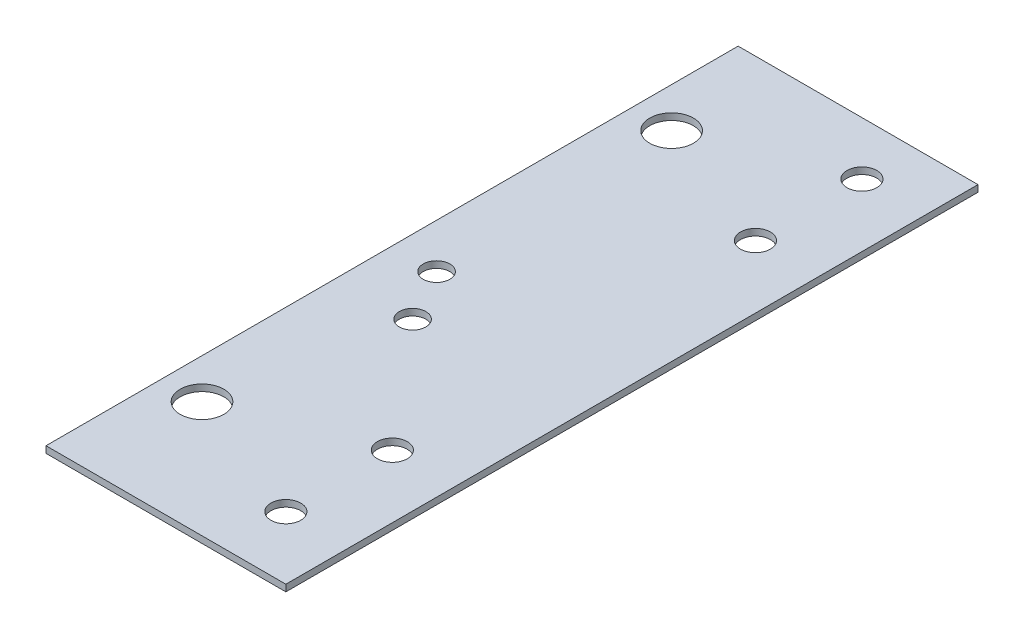
from build123d import *

# Parameters (mm, degrees)
SKETCH1_R           = 5.207
SKETCH1_R_2         = 3.556
BOSS_EXTRUDE1_DEPTH = 1.5875
SKETCH2_R           = 3.175
CUT_EXTRUDE1_DEPTH  = 2.5875
SKETCH3_R           = 3.175
CUT_EXTRUDE2_DEPTH  = 2.5875


with BuildPart() as part:
    # Sketch1 → Boss-Extrude1 (new body)
    with BuildSketch(Plane(origin=(0, 0, 0), x_dir=(1, 0, 0), z_dir=(0, 1, 0))):
        Polygon((-28.60675, 81.407), (28.60675, 81.407), (28.60675, -81.407), (28.60675, -83.693), (-28.60675, -83.693), (-28.60675, -81.407), align=None)
        with Locations((-19.08175, 56.007)):
            Circle(SKETCH1_R, mode=Mode.SUBTRACT)
        with Locations((-19.08175, -56.007)):
            Circle(SKETCH1_R, mode=Mode.SUBTRACT)
        with Locations((13.62075, 68.707)):
            Circle(SKETCH1_R_2, mode=Mode.SUBTRACT)
        with Locations((13.62075, 43.307)):
            Circle(SKETCH1_R_2, mode=Mode.SUBTRACT)
        with Locations((13.62075, -43.307)):
            Circle(SKETCH1_R_2, mode=Mode.SUBTRACT)
        with Locations((13.62075, -68.707)):
            Circle(SKETCH1_R_2, mode=Mode.SUBTRACT)
    extrude(amount=BOSS_EXTRUDE1_DEPTH)

    # Sketch2 → Cut-Extrude1 (cut, through all)
    with BuildSketch(Plane(origin=(0, 1.5875, 0), x_dir=(1, 0, 0), z_dir=(0, 1, 0))):
        with Locations((-17.992815678, -1.143)):
            Circle(SKETCH2_R)
    extrude(amount=-CUT_EXTRUDE1_DEPTH, mode=Mode.SUBTRACT)

    # Sketch3 → Cut-Extrude2 (cut, through all)
    with BuildSketch(Plane.XZ):
        with Locations((-11.01725, 13.843)):
            Circle(SKETCH3_R)
    extrude(amount=-CUT_EXTRUDE2_DEPTH, mode=Mode.SUBTRACT)


solid = part.part
